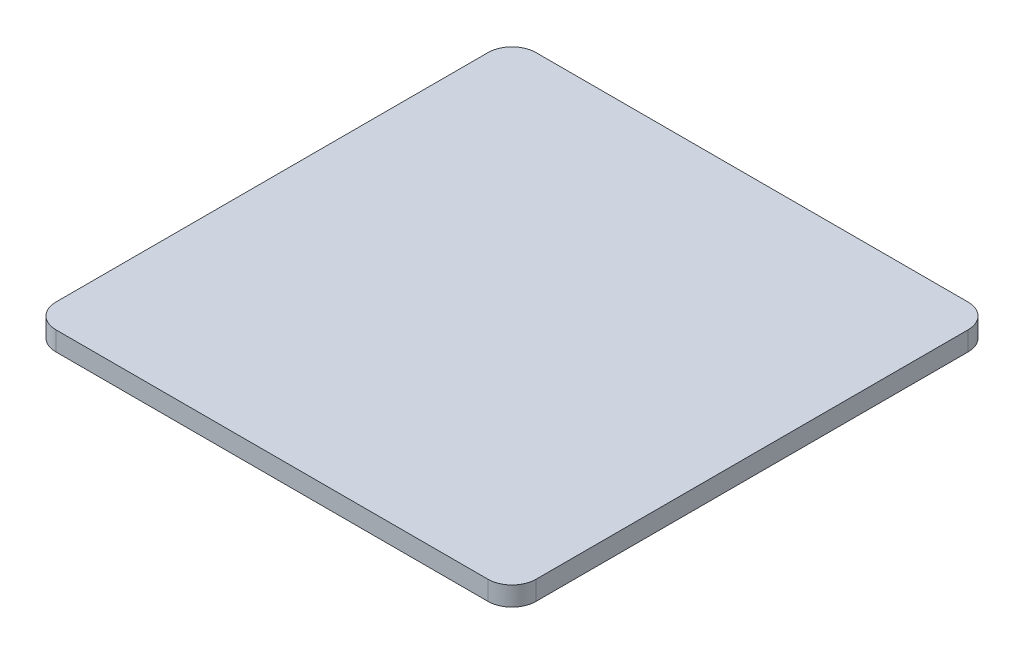
from build123d import *

# Parameters (mm, degrees)
SKETCH1_W           = 100
SKETCH1_H           = 100
BOSS_EXTRUDE1_DEPTH = 4
FILLET1_R           = 5


with BuildPart() as part:
    # Sketch1 → Boss-Extrude1 (new body)
    with BuildSketch(Plane(origin=(0, 0, 0), x_dir=(1, 0, 0), z_dir=(0, 1, 0))):
        Rectangle(SKETCH1_W, SKETCH1_H)
    extrude(amount=BOSS_EXTRUDE1_DEPTH)

    # Fillet1
    fillet1_edges = [part.edges().sort_by_distance(p)[0] for p in [
        (50, 2, 50),
        (-50, 2, 50),
        (-50, 2, -50),
        (50, 2, -50),
    ]]
    fillet(fillet1_edges, radius=FILLET1_R)


solid = part.part
